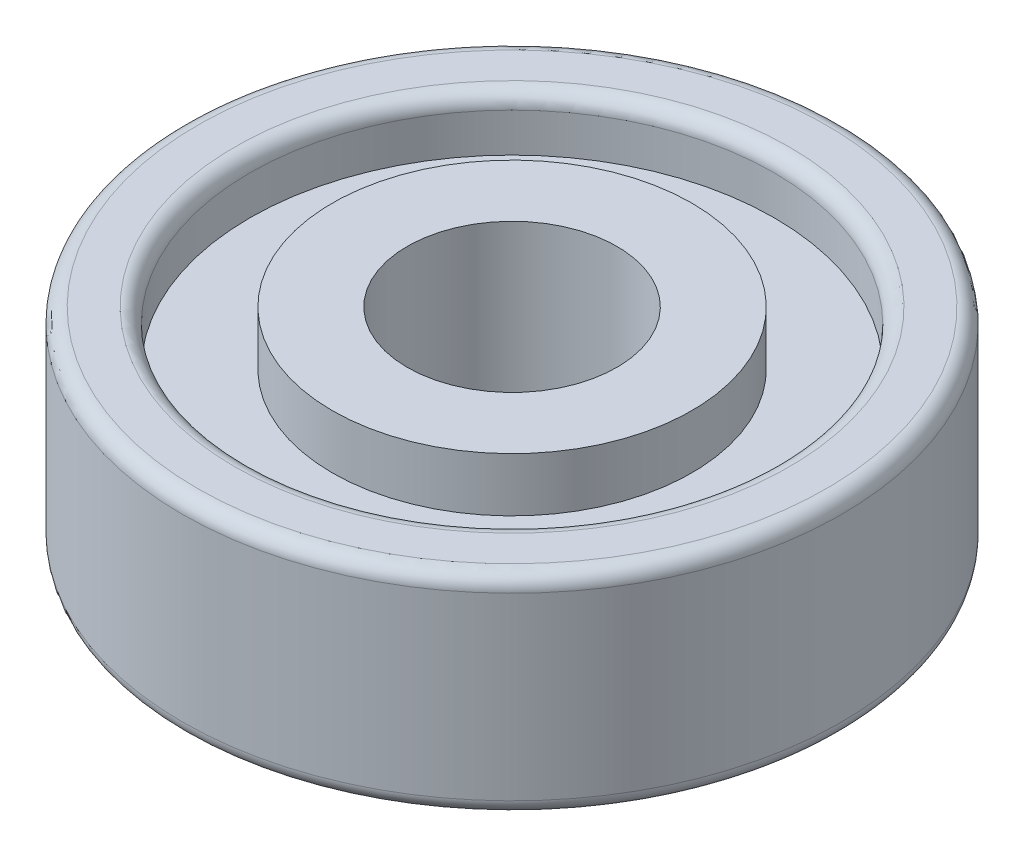
from build123d import *

# Parameters (mm, degrees)
SKETCH1_R           = 11
BOSS_EXTRUDE1_DEPTH = 3.5
SKETCH2_R           = 3.5
CUT_EXTRUDE2_DEPTH  = 8
SKETCH3_R           = 8.75
SKETCH3_R_2         = 6
CUT_EXTRUDE4_DEPTH  = 1.8
FILLET1_R           = 0.5


with BuildPart() as part:
    # Sketch1 → Boss-Extrude1 (new body, symmetric)
    with BuildSketch(Plane(origin=(0, 0, 0), x_dir=(1, 0, 0), z_dir=(0, 1, 0))):
        Circle(SKETCH1_R)
    extrude(amount=BOSS_EXTRUDE1_DEPTH, both=True)

    # Sketch2 → Cut-Extrude2 (cut, through all)
    with BuildSketch(Plane(origin=(0, 3.5, 0), x_dir=(1, 0, 0), z_dir=(0, 1, 0))):
        Circle(SKETCH2_R)
    extrude(amount=-CUT_EXTRUDE2_DEPTH, mode=Mode.SUBTRACT)

    # Sketch3 → Cut-Extrude4 (cut)
    with BuildSketch(Plane(origin=(0, 3.5, 0), x_dir=(1, 0, 0), z_dir=(0, 1, 0))):
        Circle(SKETCH3_R)
        Circle(SKETCH3_R_2, mode=Mode.SUBTRACT)
    cut_extrude4 = extrude(amount=-CUT_EXTRUDE4_DEPTH, mode=Mode.SUBTRACT)

    # Mirror1: Cut-Extrude4 across plane
    add(cut_extrude4.mirror(Plane.ZX), mode=Mode.SUBTRACT)

    # Fillet1
    fillet1_edges = [part.edges().sort_by_distance(p)[0] for p in [
        (-8.75, 3.5, 0),
        (-11, -3.5, 0),
        (-8.75, -3.5, 0),
        (-11, 3.5, 0),
    ]]
    fillet(fillet1_edges, radius=FILLET1_R)


solid = part.part
